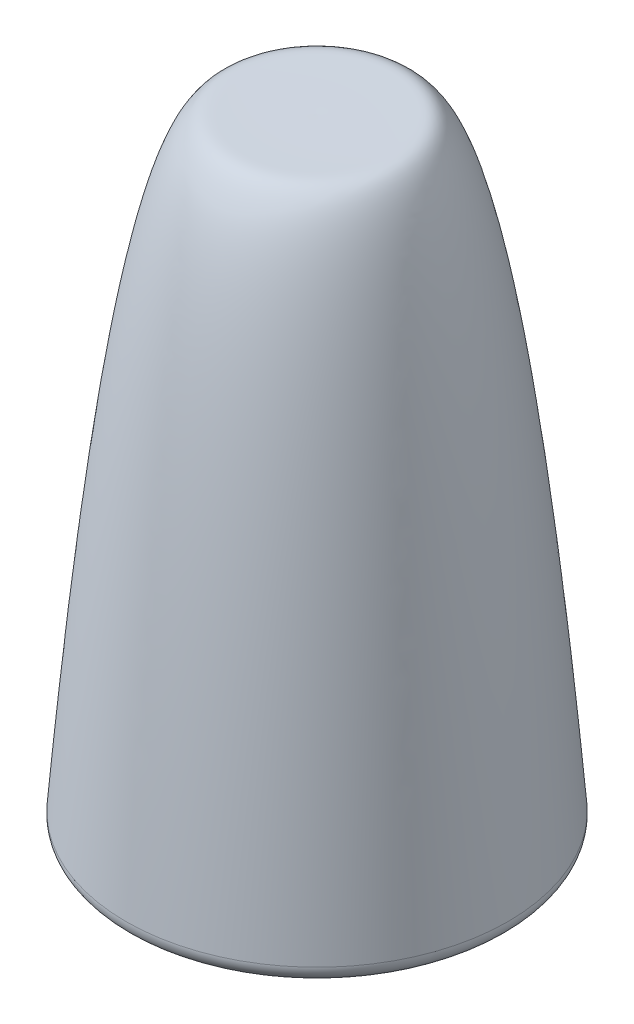
from build123d import *

# Parameters (mm, degrees)
FILETE1_R             = 0.5
ESBO_O2_R             = 1.5
CORTE_EXTRUS_O1_DEPTH = 5


with BuildPart() as part:
    # Esboço1 → Revolução1 (revolve)
    with BuildSketch(Plane.XY):
        with BuildLine():
            Line((0, 0), (6.2, 0))
            add(Edge.make_bspline(
                [(0, 20), (0.432351955, 20.004832283), (1.967438722, 19.998604271), (3.665241094, 20.06332036), (5.07224731, 14.471938807), (6.2, 0)],
                knots=[0, 0, 0, 0, 0.288601343, 0.388601343, 1, 1, 1, 1], degree=3))
            Line((0, 20), (0, 0))
        make_face()
    revolve(axis=Axis((0, 20, 0), (0, -1, 0)))

    # Filete1
    filete1_edges = [part.edges().sort_by_distance(p)[0] for p in [
        (-6.2, 0, 0),
    ]]
    fillet(filete1_edges, radius=FILETE1_R)

    # Esboço2 → Corte-extrusão1 (cut)
    with BuildSketch(Plane.XZ):
        Circle(ESBO_O2_R)
    extrude(amount=-CORTE_EXTRUS_O1_DEPTH, mode=Mode.SUBTRACT)


solid = part.part
